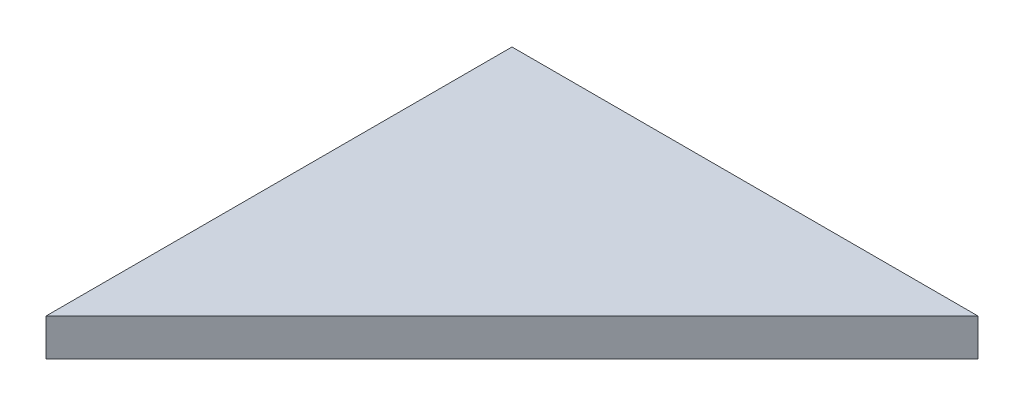
from build123d import *

# Parameters (mm, degrees)
BOSS_EXTRUDE1_DEPTH = 6.4


with BuildPart() as part:
    # Sketch1 → Boss-Extrude1 (new body)
    with BuildSketch(Plane(origin=(0, 6.4, 0), x_dir=(1, 0, 0), z_dir=(0, 1, 0))):
        Polygon((0, 100), (0, 20), (80, 100), align=None)
    extrude(amount=-BOSS_EXTRUDE1_DEPTH)


solid = part.part
